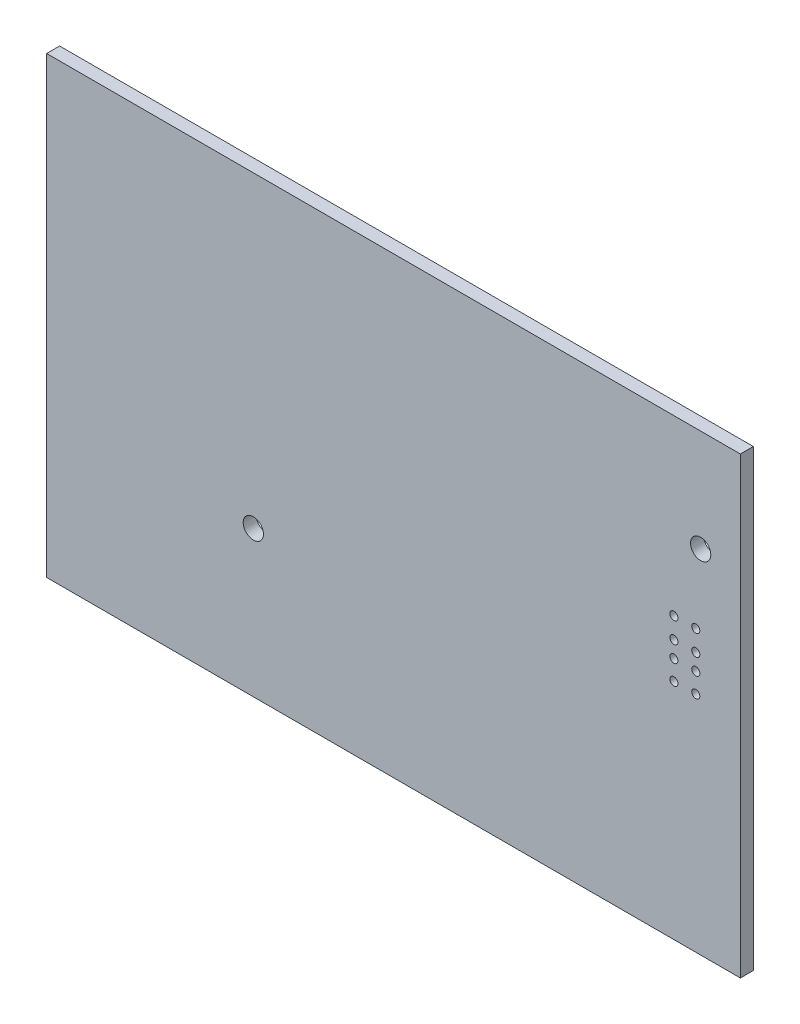
from build123d import *

# Parameters (mm, degrees)
ESBO_O1_W                = 85.6
ESBO_O1_H                = 56
RESSALTO_EXTRUS_O1_DEPTH = 1.6
ESBO_O2_R                = 0.5
CORTE_EXTRUS_O1_DEPTH    = 2
ESBO_O3_R                = 1.25
CORTE_EXTRUS_O2_DEPTH    = 10


with BuildPart() as part:
    # Esboço1 → Ressalto-extrusão1 (new body)
    with BuildSketch(Plane(origin=(0, 0, 0), x_dir=(-1, 0, 0), z_dir=(0, 0, -1))):
        with Locations((0.3, 0)):
            Rectangle(ESBO_O1_W, ESBO_O1_H)
    extrude(amount=-RESSALTO_EXTRUS_O1_DEPTH)

    # Esboço2 → Corte-extrusão1 (cut)
    with BuildSketch(Plane.XY.offset(1.6)):
        with Locations((37, 6.6)):
            Circle(ESBO_O2_R)
        with Locations((34.3, 6.6)):
            Circle(ESBO_O2_R)
        with Locations((34.3, 4.05)):
            Circle(ESBO_O2_R)
        with Locations((34.3, 2.04)):
            Circle(ESBO_O2_R)
        with Locations((34.3, -0.4)):
            Circle(ESBO_O2_R)
        with Locations((37, 4.05)):
            Circle(ESBO_O2_R)
        with Locations((37, 2.04)):
            Circle(ESBO_O2_R)
        with Locations((37, -0.4)):
            Circle(ESBO_O2_R)
    extrude(amount=-CORTE_EXTRUS_O1_DEPTH, mode=Mode.SUBTRACT)

    # Esboço3 → Corte-extrusão2 (cut)
    with BuildSketch(Plane.XY.offset(1.6)):
        with Locations((37.6, 15.4)):
            Circle(ESBO_O3_R)
        with Locations((-17.6, -10)):
            Circle(ESBO_O3_R)
    extrude(amount=-CORTE_EXTRUS_O2_DEPTH, mode=Mode.SUBTRACT)


solid = part.part
